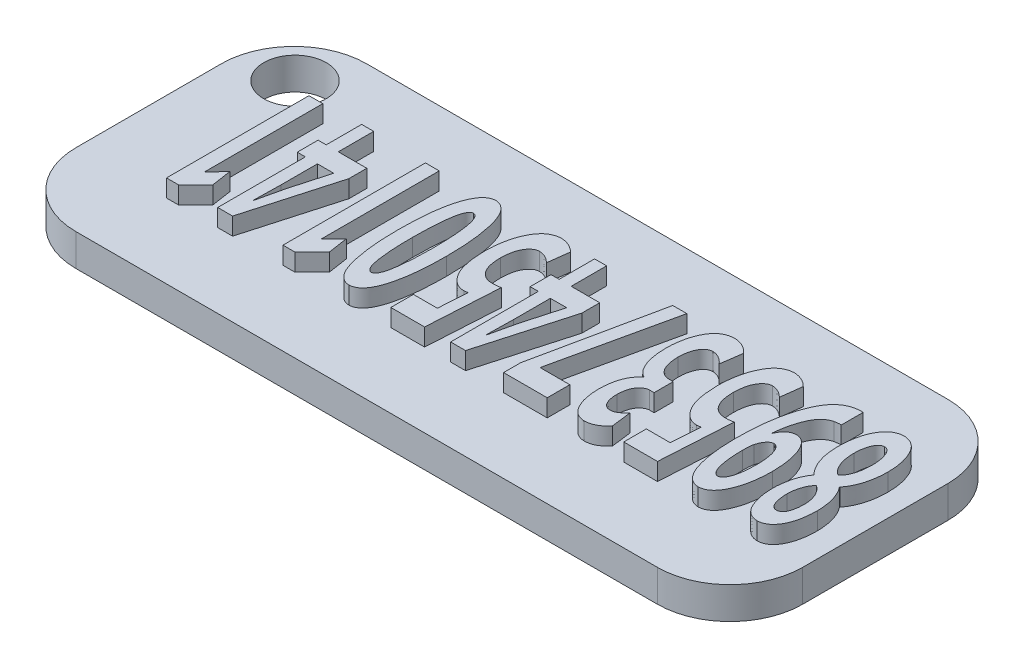
from build123d import *

# Parameters (mm, degrees)
SKETCH_1_W              = 50
SKETCH_1_H              = 20
EXTRUDE_1_DEPTH         = 2.2
FILLET_1_R              = 5
FILLET_2_R              = 5
FILLET_3_R              = 5
FILLET_4_R              = 5
SKETCH_4_R              = 2.151855383
CUT_EXTRUDE_1_DEPTH     = 3
EXTRUDE_1056_DEPTH      = 1.2
EXTRUDE_1056_DEPTH_BACK = 1.2


with BuildPart() as part:
    # Эскиз1 → Бобышка-Вытянуть1 (new body)
    with BuildSketch(Plane(origin=(0, 0, 0), x_dir=(1, 0, 0), z_dir=(0, 1, 0))):
        with Locations((25, 10)):
            Rectangle(SKETCH_1_W, SKETCH_1_H)
    extrude(amount=EXTRUDE_1_DEPTH)

    # Скругление1
    fillet_1_edges = [part.edges().sort_by_distance(p)[0] for p in [
        (0, 1.1, -20),
    ]]
    fillet(fillet_1_edges, radius=FILLET_1_R)

    # Скругление2
    fillet_2_edges = [part.edges().sort_by_distance(p)[0] for p in [
        (0, 1.1, 0),
    ]]
    fillet(fillet_2_edges, radius=FILLET_2_R)

    # Скругление3
    fillet_3_edges = [part.edges().sort_by_distance(p)[0] for p in [
        (50, 1.1, -20),
    ]]
    fillet(fillet_3_edges, radius=FILLET_3_R)

    # Скругление4
    fillet_4_edges = [part.edges().sort_by_distance(p)[0] for p in [
        (50, 1.1, 0),
    ]]
    fillet(fillet_4_edges, radius=FILLET_4_R)

    # Эскиз4 → Вырез-Вытянуть1 (cut)
    with BuildSketch(Plane(origin=(0, 2.2, 0), x_dir=(1, 0, 0), z_dir=(0, 1, 0))):
        with Locations((3.542470198, 16.528352227)):
            Circle(SKETCH_4_R)
    extrude(amount=-CUT_EXTRUDE_1_DEPTH, mode=Mode.SUBTRACT)

    # Эскиз5 → Extrude 1056 (add, two sides: drawn at the far end of the back side and taken through both)
    # profile 1 of 11: a face of its own
    with BuildSketch(Plane.XZ.offset(-2.2).offset(-EXTRUDE_1056_DEPTH_BACK)):
        with BuildLine():
            add(Edge.make_bspline(
                [(46.078309947, -9.677843866), (46.027974113, -9.605172508), (45.925734825, -9.457566573), (45.797719515, -9.21403545), (45.690766361, -8.949790128), (45.605330166, -8.667262078), (45.538818282, -8.374682095), (45.489532793, -8.076942657), (45.45786786, -7.777208198), (45.454564992, -7.576119586), (45.452912137, -7.475488811)],
                knots=[0, 0, 0, 0, 0.911528828, 1.851445597, 2.831681584, 3.849114504, 4.893651631, 5.925632796, 6.961924405, 8, 8, 8, 8], degree=3))
            add(Edge.make_bspline(
                [(45.452912137, -7.475488811), (45.456739433, -7.319432744), (45.464194853, -7.015441717), (45.526511786, -6.573878797), (45.63311746, -6.161319712), (45.753938359, -5.83962289), (45.873267915, -5.604845892), (45.977498211, -5.452969286), (46.093544961, -5.323103196), (46.221115754, -5.213766333), (46.361470193, -5.126354365), (46.514657083, -5.061353085), (46.680172404, -5.019646003), (46.795068916, -5.009135957), (46.853741958, -5.003768899)],
                knots=[0, 0, 0, 0, 1.791554521, 3.489877151, 5.107255168, 6.676714242, 7.425606061, 8.126241729, 8.785513885, 9.420356286, 10.049181088, 10.676513228, 11.324148379, 12, 12, 12, 12], degree=3))
            add(Edge.make_bspline(
                [(46.853741958, -5.003768899), (46.90797993, -5.007260305), (47.014463515, -5.014114866), (47.169787234, -5.050784431), (47.315929588, -5.110360712), (47.455258419, -5.189599), (47.583778459, -5.293674812), (47.705715522, -5.417268753), (47.817999658, -5.563759963), (47.924291395, -5.729516874), (48.016616167, -5.916192509), (48.100737096, -6.118543686), (48.169034399, -6.33794704), (48.228390088, -6.572481678), (48.272394452, -6.824061429), (48.306605506, -7.091379936), (48.326940882, -7.375267295), (48.331443098, -7.569726588), (48.333757313, -7.669681908)],
                knots=[0, 0, 0, 0, 0.776059093, 1.523610694, 2.26943235, 3.026161316, 3.806370488, 4.625991605, 5.503091466, 6.44030775, 7.436849706, 8.476373815, 9.570387437, 10.718835958, 11.933161742, 13.219262995, 14.570654791, 16, 16, 16, 16], degree=3))
            add(Edge.make_bspline(
                [(48.333757313, -7.669681908), (48.332400882, -7.773485108), (48.329714157, -7.979091408), (48.294470298, -8.282880004), (48.248183965, -8.579721921), (48.175551215, -8.86483122), (48.087174996, -9.135586497), (47.976756913, -9.385857701), (47.850277624, -9.616246555), (47.747160445, -9.753473674), (47.696502294, -9.820888941)],
                knots=[0, 0, 0, 0, 1.089978603, 2.15895528, 3.20972959, 4.244258845, 5.246508595, 6.198517637, 7.11498969, 8, 8, 8, 8], degree=3))
            Line((47.696502294, -9.820888941), (47.695145343, -9.85936227))
            add(Edge.make_bspline(
                [(47.695145343, -9.85936227), (47.747554237, -9.926459085), (47.856031089, -10.065337253), (47.992318934, -10.306361212), (48.120543883, -10.577558027), (48.235291236, -10.883599416), (48.332007715, -11.222904393), (48.400135986, -11.596003837), (48.444033938, -12.001236193), (48.450872319, -12.282433004), (48.454420985, -12.428355484)],
                knots=[0, 0, 0, 0, 0.747893007, 1.548002103, 2.428220339, 3.385024111, 4.419108458, 5.527032265, 6.716693888, 8, 8, 8, 8], degree=3))
            add(Edge.make_bspline(
                [(48.454420985, -12.428355484), (48.452674256, -12.516993812), (48.449226519, -12.691950305), (48.430923326, -12.949468758), (48.398000408, -13.197850059), (48.355874941, -13.436766086), (48.298960072, -13.665970943), (48.22900655, -13.885768002), (48.146139953, -14.095954879), (48.053448211, -14.295680741), (47.946991827, -14.478130498), (47.827908731, -14.639709615), (47.697781171, -14.778860945), (47.554387512, -14.893967333), (47.398514091, -14.984872048), (47.231251794, -15.053623861), (47.051286399, -15.097807415), (46.926883157, -15.107935165), (46.863168807, -15.113122193)],
                knots=[0, 0, 0, 0, 1.235435888, 2.438533473, 3.595508883, 4.725923701, 5.817781028, 6.884189936, 7.938117332, 8.96461166, 9.950003493, 10.876660607, 11.756436375, 12.597656396, 13.429845812, 14.262588117, 15.110167343, 16, 16, 16, 16], degree=3))
            add(Edge.make_bspline(
                [(46.863168807, -15.113122193), (46.80262288, -15.109171079), (46.684044908, -15.101432903), (46.511067483, -15.060678112), (46.347933835, -14.995360647), (46.191896755, -14.909032346), (46.047301537, -14.794897335), (45.911617757, -14.658556004), (45.784541788, -14.498597289), (45.668579213, -14.315558168), (45.563753042, -14.112223731), (45.470997983, -13.891170782), (45.394091896, -13.651866208), (45.330756558, -13.395988548), (45.279593831, -13.122797621), (45.242938773, -12.833195306), (45.217255905, -12.526213109), (45.213510802, -12.315917003), (45.211584793, -12.207767208)],
                knots=[0, 0, 0, 0, 0.789717121, 1.546644996, 2.30406014, 3.074123165, 3.86213959, 4.696104222, 5.576133471, 6.519015237, 7.51540899, 8.554319549, 9.6395583, 10.787721216, 11.987677943, 13.259577382, 14.590672234, 16, 16, 16, 16], degree=3))
            add(Edge.make_bspline(
                [(45.211584793, -12.207767208), (45.21631399, -12.061200702), (45.225433942, -11.778556663), (45.273766155, -11.372768263), (45.352120596, -11.002667897), (45.459635252, -10.669550107), (45.589719445, -10.373513923), (45.734618791, -10.113421233), (45.894005329, -9.888382936), (46.01865144, -9.764048816), (46.078854937, -9.703996008)],
                knots=[0, 0, 0, 0, 1.293490065, 2.494412024, 3.600539669, 4.62641707, 5.577396771, 6.448871158, 7.250811916, 8, 8, 8, 8], degree=3))
            Line((46.078854937, -9.703996008), (46.078309947, -9.677843866))
        make_face()
        with BuildLine():
            add(Edge.make_bspline(
                [(46.83621391, -13.800904757), (46.862390214, -13.798185585), (46.913759078, -13.792849434), (46.987088364, -13.766571208), (47.056547102, -13.729238508), (47.117966898, -13.673680896), (47.180206287, -13.610280654), (47.232947149, -13.529565327), (47.285573124, -13.438614817), (47.344553499, -13.294330749), (47.410925257, -13.095175517), (47.463520234, -12.833038866), (47.498548764, -12.547453652), (47.502265453, -12.348657789), (47.504194566, -12.245474606)],
                knots=[0, 0, 0, 0, 0.516878197, 1.014331308, 1.524422578, 2.060470795, 2.63878414, 3.270961343, 3.953097661, 4.707736148, 6.337157177, 8.083774507, 9.967318802, 12, 12, 12, 12], degree=3))
            add(Edge.make_bspline(
                [(47.504194566, -12.245474606), (47.501605234, -12.149267424), (47.496550758, -11.961467335), (47.469393374, -11.687559734), (47.419429409, -11.430678791), (47.355280098, -11.191444527), (47.271814748, -10.975113826), (47.170826099, -10.787544871), (47.053714874, -10.629827493), (46.959591571, -10.548418242), (46.914073794, -10.509048947)],
                knots=[0, 0, 0, 0, 1.22142396, 2.384266159, 3.488789828, 4.539640758, 5.524731502, 6.424298786, 7.237995119, 8, 8, 8, 8], degree=3))
            add(Edge.make_bspline(
                [(46.914073794, -10.509048947), (46.86044007, -10.548203883), (46.750645538, -10.628358636), (46.609486585, -10.785243872), (46.482183681, -10.970250236), (46.371339819, -11.186804007), (46.277961057, -11.434662914), (46.214225457, -11.716286991), (46.172416068, -12.028695365), (46.165451114, -12.247841318), (46.161811212, -12.362367538)],
                knots=[0, 0, 0, 0, 0.764838737, 1.565714712, 2.420999668, 3.352265673, 4.366974192, 5.470323704, 6.677984882, 8, 8, 8, 8], degree=3))
            add(Edge.make_bspline(
                [(46.161811212, -12.362367538), (46.163759344, -12.457382745), (46.167514338, -12.640523049), (46.202428312, -12.9042703), (46.256201504, -13.146406235), (46.3292193, -13.363319376), (46.421100573, -13.54734881), (46.538282039, -13.686539035), (46.67973401, -13.7773093), (46.784720718, -13.793083723), (46.83621391, -13.800904757)],
                knots=[0, 0, 0, 0, 1.321228345, 2.546646677, 3.694107777, 4.76689393, 5.725035891, 6.536813707, 7.27454525, 8, 8, 8, 8], degree=3))
        make_face(mode=Mode.SUBTRACT)
        with BuildLine():
            add(Edge.make_bspline(
                [(46.886500259, -6.293647279), (46.83538083, -6.301938363), (46.734376801, -6.318320253), (46.600140532, -6.408312885), (46.493740845, -6.543789202), (46.41679896, -6.722317663), (46.358261152, -6.92709015), (46.311903706, -7.152013712), (46.285864996, -7.392535246), (46.283622758, -7.558383626), (46.282474884, -7.64328673)],
                knots=[0, 0, 0, 0, 0.765528405, 1.512564887, 2.346431841, 3.307864738, 4.394490714, 5.524415916, 6.732669124, 8, 8, 8, 8], degree=3))
            add(Edge.make_bspline(
                [(46.282474884, -7.64328673), (46.285542594, -7.725718472), (46.291533991, -7.886711995), (46.322755467, -8.121747951), (46.368092179, -8.344452345), (46.434989814, -8.55067455), (46.511234044, -8.737323134), (46.60109943, -8.897440638), (46.696643827, -9.032946341), (46.775094048, -9.101929862), (46.81226382, -9.134614305)],
                knots=[0, 0, 0, 0, 1.216519099, 2.375925702, 3.494449087, 4.564888535, 5.570675503, 6.463263841, 7.271893284, 8, 8, 8, 8], degree=3))
            add(Edge.make_bspline(
                [(46.81226382, -9.134614305), (46.862439152, -9.096350175), (46.963589503, -9.019212066), (47.096313583, -8.876918569), (47.213065342, -8.713564267), (47.315895318, -8.52958974), (47.398878962, -8.323302575), (47.458545593, -8.094677067), (47.497098, -7.844424879), (47.501769248, -7.669832657), (47.504194566, -7.579184154)],
                knots=[0, 0, 0, 0, 0.854607252, 1.722835104, 2.626488507, 3.572752242, 4.57465509, 5.633219383, 6.771164507, 8, 8, 8, 8], degree=3))
            add(Edge.make_bspline(
                [(47.504194566, -7.579184154), (47.503195757, -7.499277873), (47.501255068, -7.344019773), (47.473234473, -7.117775601), (47.431519103, -6.903753043), (47.369090488, -6.707727668), (47.290569229, -6.53547269), (47.182295761, -6.403004689), (47.043184988, -6.318466445), (46.940284878, -6.303102084), (46.887678615, -6.295247266)],
                knots=[0, 0, 0, 0, 1.230812713, 2.391472128, 3.50850541, 4.586815455, 5.557221012, 6.409314627, 7.186784035, 8, 8, 8, 8], degree=3))
            Line((46.887678615, -6.295247266), (46.886500259, -6.293647279))
        make_face(mode=Mode.SUBTRACT)
    # profile 2 of 11: a face of its own
    with BuildSketch(Plane.XZ.offset(-2.2).offset(-EXTRUDE_1056_DEPTH_BACK)):
        with BuildLine():
            add(Edge.make_bspline(
                [(44.04725437, -15.11174683), (43.987385205, -15.114070393), (43.868898808, -15.118668932), (43.693434551, -15.103937408), (43.523252435, -15.077828695), (43.358741609, -15.039003764), (43.201388033, -14.983318238), (43.050111553, -14.915129471), (42.903936107, -14.834674512), (42.766996185, -14.736787277), (42.632629914, -14.629426485), (42.508059907, -14.504726533), (42.38788946, -14.367318384), (42.273368197, -14.217136563), (42.16508345, -14.052358087), (42.066568067, -13.872002181), (41.96939987, -13.68052939), (41.851289199, -13.402249017), (41.717343953, -13.031760823), (41.577455337, -12.561667209), (41.462107324, -12.061386408), (41.365507994, -11.533031322), (41.293318956, -10.975995836), (41.240314731, -10.390514117), (41.210397464, -9.775330417), (41.207191415, -9.35523444), (41.205550872, -9.140270414)],
                knots=[0, 0, 0, 0, 0.587702947, 1.163116348, 1.725075362, 2.277262808, 2.819713187, 3.360969282, 3.905101247, 4.454524283, 5.011482261, 5.591737658, 6.182009412, 6.802709751, 7.444427068, 8.115602503, 8.819201884, 9.551563824, 11.081795736, 12.684480665, 14.363626865, 16.119590269, 17.955514458, 19.875934814, 21.889706872, 24, 24, 24, 24], degree=3))
            add(Edge.make_bspline(
                [(41.205550872, -9.140270414), (41.207264897, -8.991309733), (41.210614758, -8.700183418), (41.228928778, -8.27442403), (41.26139615, -7.870179001), (41.303851059, -7.487012124), (41.35985007, -7.12516581), (41.429753321, -6.785560877), (41.510350616, -6.467461477), (41.603134364, -6.172814895), (41.708826173, -5.906123561), (41.827749924, -5.671195277), (41.958955197, -5.470530026), (42.102547312, -5.302101472), (42.26283362, -5.173038944), (42.433532632, -5.075831142), (42.618009403, -5.01296775), (42.746684608, -5.000605939), (42.81188601, -4.994342049)],
                knots=[0, 0, 0, 0, 1.488694986, 2.909481093, 4.257746305, 5.540848802, 6.761339651, 7.915469393, 9.004609899, 10.039448099, 11.000449599, 11.868389147, 12.666188125, 13.391717201, 14.070478316, 14.711614416, 15.347158253, 16, 16, 16, 16], degree=3))
            add(Edge.make_bspline(
                [(42.81188601, -4.994342049), (42.873943174, -5.000099892), (42.997342197, -5.011549209), (43.174435585, -5.071753842), (43.341841896, -5.156147597), (43.497681637, -5.27312241), (43.642287555, -5.41903082), (43.776639778, -5.595135643), (43.901300582, -5.799757373), (44.011533243, -6.03278609), (44.113476948, -6.28555358), (44.198583084, -6.556030295), (44.274785722, -6.839444532), (44.337084136, -7.137093239), (44.382818759, -7.449561619), (44.419726254, -7.775163248), (44.439445614, -8.115654083), (44.444116993, -8.347137517), (44.446501695, -8.465307997)],
                knots=[0, 0, 0, 0, 0.71661271, 1.42496533, 2.141431373, 2.872130828, 3.661492946, 4.503891963, 5.421382964, 6.41994004, 7.473922347, 8.56282292, 9.6881508, 10.858187346, 12.067902601, 13.329498283, 14.63672978, 16, 16, 16, 16], degree=3))
            add(Edge.make_bspline(
                [(44.446501695, -8.465307997), (44.444301581, -8.579725962), (44.440018776, -8.802455229), (44.418138685, -9.126841338), (44.389744776, -9.432845618), (44.346232134, -9.719112434), (44.291514129, -9.986576149), (44.226515668, -10.234971415), (44.149036141, -10.464286834), (44.061521886, -10.673296099), (43.963022591, -10.859813171), (43.86081538, -11.024451663), (43.750302846, -11.165118524), (43.632325733, -11.27981019), (43.50792487, -11.371672429), (43.375998762, -11.435440305), (43.238321206, -11.480471442), (43.142806007, -11.486436477), (43.094691492, -11.489441284)],
                knots=[0, 0, 0, 0, 1.529770763, 2.977895321, 4.345668482, 5.637335493, 6.846838563, 7.994249315, 9.067689445, 10.080490039, 11.020068362, 11.884879202, 12.668265517, 13.405073479, 14.079029672, 14.725341234, 15.357907549, 16, 16, 16, 16], degree=3))
            add(Edge.make_bspline(
                [(43.094691492, -11.489441284), (43.044787182, -11.486183321), (42.945933546, -11.479729739), (42.803226891, -11.439100379), (42.670705849, -11.373559165), (42.548260623, -11.283451948), (42.439085027, -11.168339541), (42.333351592, -11.038338918), (42.241947327, -10.886319281), (42.190018525, -10.776615668), (42.163318771, -10.720210373)],
                knots=[0, 0, 0, 0, 0.935406275, 1.852912324, 2.759079899, 3.694486174, 4.685786001, 5.725263117, 6.830419519, 8, 8, 8, 8], degree=3))
            Line((42.163318771, -10.720210373), (42.143203863, -10.732850085))
            add(Edge.make_bspline(
                [(42.143203863, -10.732850085), (42.152913081, -10.826145832), (42.171961613, -11.009182943), (42.213021068, -11.276889607), (42.256329034, -11.533427069), (42.312327657, -11.777714281), (42.373431464, -12.010753199), (42.443989973, -12.232601603), (42.520328195, -12.443143418), (42.604992277, -12.640929958), (42.696024941, -12.824197987), (42.797560211, -12.98838531), (42.907535712, -13.132919259), (43.024857499, -13.258958894), (43.151200313, -13.365300223), (43.286637025, -13.450625789), (43.428878747, -13.518420365), (43.529094466, -13.547109732), (43.579231551, -13.561462782)],
                knots=[0, 0, 0, 0, 1.339989936, 2.628928885, 3.868993049, 5.056241457, 6.208438896, 7.310307185, 8.381264534, 9.407037606, 10.382860463, 11.30231499, 12.160773156, 12.973890012, 13.757980097, 14.51278177, 15.255957167, 16, 16, 16, 16], degree=3))
            add(Edge.make_bspline(
                [(43.579231551, -13.561462782), (43.61258245, -13.566861786), (43.67367764, -13.576752169), (43.756732427, -13.593836438), (43.824452891, -13.601489775), (43.891708091, -13.613413366), (43.965642464, -13.61504435), (44.021131507, -13.605697441), (44.048688651, -13.601055549)],
                knots=[0, 0, 0, 0, 1.282317147, 2.349064382, 3.21602214, 3.867087612, 4.940746315, 6, 6, 6, 6], degree=3))
            Line((44.048688651, -13.601055549), (44.04725437, -15.11174683))
        make_face()
        with BuildLine():
            add(Edge.make_bspline(
                [(42.844590917, -6.304677798), (42.81632972, -6.308919917), (42.759015095, -6.317523072), (42.678836933, -6.357293238), (42.605990003, -6.416423603), (42.536602226, -6.493216758), (42.476050485, -6.592472346), (42.419178939, -6.710531156), (42.368846462, -6.849011498), (42.308227289, -7.066665145), (42.244553984, -7.373100249), (42.194071408, -7.777220869), (42.161821034, -8.225345058), (42.15785408, -8.538776352), (42.155777292, -8.702864602)],
                knots=[0, 0, 0, 0, 0.388324956, 0.787535614, 1.2030177, 1.664837744, 2.193361997, 2.784441419, 3.452382468, 4.202091393, 5.868356787, 7.720494359, 9.759583653, 12, 12, 12, 12], degree=3))
            add(Edge.make_bspline(
                [(42.155777292, -8.702864602), (42.155368544, -8.74812072), (42.154596287, -8.833624136), (42.15968612, -8.954239716), (42.162435199, -9.060539025), (42.170279424, -9.177455748), (42.179085395, -9.300512339), (42.199485933, -9.390539813), (42.208567648, -9.430617376)],
                knots=[0, 0, 0, 0, 1.11380462, 2.104336476, 2.971181265, 3.730606527, 4.989733304, 6, 6, 6, 6], degree=3))
            add(Edge.make_bspline(
                [(42.208567648, -9.430617376), (42.238302449, -9.525684566), (42.295931093, -9.709933092), (42.4157911, -9.915830309), (42.528538944, -10.050337156), (42.621005158, -10.125337554), (42.723563966, -10.173398169), (42.796336215, -10.182241067), (42.832625079, -10.186650697)],
                knots=[0, 0, 0, 0, 1.717293694, 3.328265295, 4.075010403, 4.73980506, 5.371586794, 6, 6, 6, 6], degree=3))
            add(Edge.make_bspline(
                [(42.832625079, -10.186650697), (42.857327254, -10.184568066), (42.906667609, -10.1804082), (42.978465354, -10.154699735), (43.044277372, -10.112341419), (43.106396021, -10.054870548), (43.165721311, -9.984224083), (43.221107135, -9.897287482), (43.271162554, -9.795137333), (43.33631677, -9.632755834), (43.402506594, -9.394999705), (43.459803499, -9.070602549), (43.494534602, -8.697313717), (43.499373301, -8.432077134), (43.501931386, -8.291853969)],
                knots=[0, 0, 0, 0, 0.413789282, 0.826506569, 1.261562931, 1.716042024, 2.238855857, 2.802250335, 3.437615293, 4.141140511, 5.729823065, 7.558733105, 9.652026376, 12, 12, 12, 12], degree=3))
            add(Edge.make_bspline(
                [(43.501931386, -8.291853969), (43.499172297, -8.153522521), (43.493908565, -7.889616713), (43.460775977, -7.513375446), (43.405536667, -7.177101272), (43.340129957, -6.924955276), (43.279157951, -6.746836863), (43.227842301, -6.634724435), (43.176350338, -6.536377609), (43.117340877, -6.457508469), (43.056964627, -6.392355076), (42.99033886, -6.347000991), (42.91982955, -6.316280085), (42.870621648, -6.309816763), (42.845822668, -6.306559485)],
                knots=[0, 0, 0, 0, 2.244031887, 4.281116543, 6.121417338, 7.765846703, 8.501017567, 9.171798035, 9.76494997, 10.29714384, 10.765780613, 11.198437351, 11.596041788, 12, 12, 12, 12], degree=3))
            Line((42.845822668, -6.306559485), (42.844590917, -6.304677798))
        make_face(mode=Mode.SUBTRACT)
    # profile 3 of 11: a face of its own
    with BuildSketch(Plane.XZ.offset(-2.2).offset(-EXTRUDE_1056_DEPTH_BACK)):
        with BuildLine():
            add(Edge.make_bspline(
                [(40.192335424, -10.097629571), (40.108779367, -10.080350986), (39.928861905, -10.043145792), (39.745130929, -10.038375834), (39.646727056, -10.035821107)],
                knots=[0, 0, 0, 0, 0.928826533, 2, 2, 2, 2], degree=3))
            add(Edge.make_bspline(
                [(39.646727056, -10.035821107), (39.596356053, -10.037144258), (39.498842118, -10.039705763), (39.357107939, -10.063141988), (39.225526757, -10.100461888), (39.102393915, -10.151947208), (38.989423473, -10.218450867), (38.884167932, -10.297443649), (38.791440863, -10.394209158), (38.706195987, -10.502836195), (38.633369841, -10.627502307), (38.566555859, -10.762910831), (38.512386723, -10.912277426), (38.469995342, -11.074174259), (38.433102138, -11.247566327), (38.409926726, -11.434895562), (38.394464745, -11.634355423), (38.392221711, -11.771586486), (38.391070716, -11.842005452)],
                knots=[0, 0, 0, 0, 0.971191819, 1.880143916, 2.762839131, 3.60505127, 4.447263409, 5.286327734, 6.135146923, 7.025222593, 7.94430753, 8.914969409, 9.935323239, 11.002990034, 12.142007005, 13.352662052, 14.641540791, 16, 16, 16, 16], degree=3))
            add(Edge.make_bspline(
                [(38.391070716, -11.842005452), (38.393043981, -11.909272993), (38.396884389, -12.040190474), (38.411460772, -12.23096965), (38.436079789, -12.409638534), (38.467810303, -12.575884139), (38.50725334, -12.730478322), (38.556081545, -12.872815282), (38.611926704, -13.004160281), (38.678287624, -13.120952078), (38.750159379, -13.224092842), (38.823488973, -13.316422958), (38.902159433, -13.393647183), (38.984829667, -13.455748737), (39.067355654, -13.509965552), (39.157602931, -13.541523956), (39.248784571, -13.566999866), (39.311573168, -13.569587136), (39.343182505, -13.570889631)],
                knots=[0, 0, 0, 0, 1.492946742, 2.905603862, 4.242536531, 5.492208905, 6.658933463, 7.7788985, 8.82796704, 9.820667976, 10.75276788, 11.615096908, 12.433471051, 13.189229796, 13.909019935, 14.610757751, 15.300620973, 16, 16, 16, 16], degree=3))
            add(Edge.make_bspline(
                [(39.343182505, -13.570889631), (39.38983853, -13.568380356), (39.482097569, -13.56341844), (39.617626699, -13.533825924), (39.747972164, -13.488642345), (39.908712456, -13.409054131), (40.087661862, -13.294393111), (40.206952933, -13.179946467), (40.263243007, -13.12594234)],
                knots=[0, 0, 0, 0, 0.801470045, 1.584851196, 2.37349572, 3.165310909, 4.662390589, 6, 6, 6, 6], degree=3))
            Line((40.263243007, -13.12594234), (40.449658954, -14.587103996))
            add(Edge.make_bspline(
                [(40.449658954, -14.587103996), (40.417096041, -14.621108057), (40.350838838, -14.690297629), (40.2359918, -14.783586466), (40.105123663, -14.867027635), (39.962626792, -14.946663917), (39.808394683, -15.015512651), (39.64214658, -15.060505063), (39.470306048, -15.095572759), (39.352168796, -15.099711688), (39.292277519, -15.101809973)],
                knots=[0, 0, 0, 0, 0.867626664, 1.765398496, 2.720085674, 3.726414318, 4.774902414, 5.823966795, 6.896830548, 8, 8, 8, 8], degree=3))
            add(Edge.make_bspline(
                [(39.292277519, -15.101809973), (39.221510791, -15.095970858), (39.082375373, -15.084490493), (38.881797156, -15.02715985), (38.69309556, -14.943712842), (38.515668747, -14.83081222), (38.350519784, -14.687994683), (38.199822831, -14.513981942), (38.060076919, -14.312731964), (37.933175297, -14.084880226), (37.819987239, -13.835916731), (37.719541463, -13.570860738), (37.634882259, -13.291113855), (37.565814728, -12.997565106), (37.510807312, -12.690453339), (37.471785794, -12.369443935), (37.446831675, -12.034072997), (37.442864076, -11.805599251), (37.440844297, -11.689290491)],
                knots=[0, 0, 0, 0, 0.800118372, 1.57312353, 2.341915381, 3.123472314, 3.938586515, 4.798407496, 5.715777283, 6.700728512, 7.739066045, 8.801352045, 9.899074363, 11.036803875, 12.204674243, 13.420209821, 14.686710393, 16, 16, 16, 16], degree=3))
            add(Edge.make_bspline(
                [(37.440844297, -11.689290491), (37.444230945, -11.562928248), (37.450775258, -11.318747534), (37.476688876, -10.965686938), (37.517892952, -10.637743387), (37.573539342, -10.33543868), (37.64374808, -10.057774711), (37.725222218, -9.804857657), (37.822605491, -9.576898803), (37.937227253, -9.376389846), (38.059134548, -9.199215643), (38.187289425, -9.045129367), (38.322065034, -8.915482301), (38.462376667, -8.808978448), (38.607735816, -8.723793371), (38.761174563, -8.667597532), (38.919204195, -8.631858513), (39.02687709, -8.627672895), (39.081116092, -8.625564437)],
                knots=[0, 0, 0, 0, 1.587176406, 3.067038503, 4.44328291, 5.735702164, 6.924301074, 8.037326695, 9.069410064, 10.030633494, 10.932524697, 11.767135362, 12.542965892, 13.275314645, 13.975181296, 14.649441249, 15.319671309, 16, 16, 16, 16], degree=3))
            add(Edge.make_bspline(
                [(39.081116092, -8.625564437), (39.127902894, -8.626817487), (39.219370871, -8.629267193), (39.307616765, -8.653378888), (39.350723985, -8.665157205)],
                knots=[0, 0, 0, 0, 1.023020369, 2, 2, 2, 2], degree=3))
            Line((39.350723985, -8.665157205), (39.220939099, -6.666668815))
            Line((39.220939099, -6.666668815), (37.574777364, -6.666668815))
            Line((37.574777364, -6.666668815), (37.574777364, -5.113122193))
            Line((37.574777364, -5.113122193), (39.896413365, -5.113122193))
            Line((39.896413365, -5.113122193), (40.192335424, -10.097629571))
        make_face()
    # profile 4 of 11: a face of its own
    with BuildSketch(Plane.XZ.offset(-2.2).offset(-EXTRUDE_1056_DEPTH_BACK)):
        with BuildLine():
            add(Edge.make_bspline(
                [(36.057639739, -7.064916378), (36.004306192, -7.003690436), (35.892624505, -6.875481891), (35.72708894, -6.735891329), (35.578356937, -6.638949579), (35.459759996, -6.582360446), (35.335839349, -6.547789274), (35.251248268, -6.540313379), (35.208943434, -6.536574611)],
                knots=[0, 0, 0, 0, 1.418338336, 2.970033458, 3.765529243, 4.517574839, 5.258624551, 6, 6, 6, 6], degree=3))
            add(Edge.make_bspline(
                [(35.208943434, -6.536574611), (35.152998735, -6.54167271), (35.044117165, -6.551594813), (34.8926061, -6.618443946), (34.768847334, -6.729589428), (34.671158906, -6.8764594), (34.597587843, -7.053763933), (34.543515452, -7.25598961), (34.511830683, -7.483302537), (34.507812222, -7.642554187), (34.505700468, -7.726243005)],
                knots=[0, 0, 0, 0, 0.872432656, 1.69795961, 2.532006638, 3.435155328, 4.428047478, 5.515317144, 6.694266783, 8, 8, 8, 8], degree=3))
            add(Edge.make_bspline(
                [(34.505700468, -7.726243005), (34.508471659, -7.782825374), (34.513867604, -7.893000169), (34.527817212, -8.052461919), (34.551921672, -8.200738881), (34.58698832, -8.336185), (34.624562342, -8.461592471), (34.675272375, -8.573741601), (34.730317281, -8.67590245), (34.814731398, -8.790362524), (34.925894879, -8.909608594), (35.070192861, -9.01539981), (35.220118195, -9.084666019), (35.323911958, -9.092876863), (35.374855983, -9.096906907)],
                knots=[0, 0, 0, 0, 1.14248271, 2.224593996, 3.226858075, 4.167522928, 5.045377976, 5.862577234, 6.645541848, 7.380784149, 8.725617819, 9.914678345, 10.976483021, 12, 12, 12, 12], degree=3))
            Line((35.374855983, -9.096906907), (35.682955617, -9.095023378))
            Line((35.682955617, -9.095023378), (35.682955617, -10.407240815))
            Line((35.682955617, -10.407240815), (35.354868116, -10.407240815))
            add(Edge.make_bspline(
                [(35.354868116, -10.407240815), (35.292198871, -10.411724456), (35.166187213, -10.420739902), (34.987264381, -10.503640202), (34.822098399, -10.631771995), (34.701723239, -10.776951097), (34.613516238, -10.915119763), (34.555184208, -11.036792837), (34.50709821, -11.171124914), (34.464913906, -11.318370985), (34.431559564, -11.479055422), (34.40787905, -11.653608291), (34.390095779, -11.840406568), (34.38675921, -11.969537942), (34.385036796, -12.036198549)],
                knots=[0, 0, 0, 0, 1.0725391, 2.156599005, 3.328049282, 4.646656099, 5.375165082, 6.143613012, 6.960669464, 7.826032993, 8.775492873, 9.77952784, 10.853740813, 12, 12, 12, 12], degree=3))
            add(Edge.make_bspline(
                [(34.385036796, -12.036198549), (34.38719891, -12.136910997), (34.391381021, -12.33171607), (34.433975166, -12.612389019), (34.501024159, -12.870937019), (34.580292765, -13.069012036), (34.659721163, -13.209687844), (34.722594072, -13.303047591), (34.795370454, -13.381550798), (34.87581608, -13.446156629), (34.961996134, -13.499725402), (35.056496227, -13.53758635), (35.156821986, -13.562620732), (35.226397309, -13.568104494), (35.26173379, -13.570889631)],
                knots=[0, 0, 0, 0, 1.856984394, 3.59190931, 5.223149363, 6.77779583, 7.50984741, 8.201383688, 8.849567299, 9.476129889, 10.100543029, 10.714205536, 11.346960239, 12, 12, 12, 12], degree=3))
            add(Edge.make_bspline(
                [(35.26173379, -13.570889631), (35.309131881, -13.56744212), (35.403932228, -13.560546795), (35.542491113, -13.521446089), (35.679540762, -13.470649809), (35.807364001, -13.394997675), (35.927876633, -13.313281413), (36.03340052, -13.222362125), (36.129087399, -13.134414947), (36.181273063, -13.068801619), (36.2063041, -13.037329955)],
                knots=[0, 0, 0, 0, 1.017995082, 2.03607963, 3.078738206, 4.148474372, 5.215482485, 6.202219836, 7.13768843, 8, 8, 8, 8], degree=3))
            Line((36.2063041, -13.037329955), (36.41789268, -14.499887228))
            add(Edge.make_bspline(
                [(36.41789268, -14.499887228), (36.38559447, -14.541328866), (36.319602606, -14.626002628), (36.196722354, -14.735146303), (36.06093928, -14.838442716), (35.908777731, -14.927409461), (35.744999595, -15.004481394), (35.569667144, -15.05776883), (35.385703099, -15.093625419), (35.260021987, -15.099040553), (35.195745844, -15.101809973)],
                knots=[0, 0, 0, 0, 0.892743867, 1.824058698, 2.786979092, 3.794344992, 4.818837677, 5.861109463, 6.906123353, 8, 8, 8, 8], degree=3))
            add(Edge.make_bspline(
                [(35.195745844, -15.101809973), (35.127015534, -15.096686821), (34.991935444, -15.086617962), (34.795999651, -15.041034136), (34.61312012, -14.967991605), (34.4421978, -14.872100926), (34.285330697, -14.748099556), (34.14018536, -14.600699387), (34.007042192, -14.427314201), (33.890681147, -14.228757005), (33.783604052, -14.013523457), (33.690962196, -13.782736443), (33.615092115, -13.538169594), (33.547123489, -13.282152932), (33.500563997, -13.011195372), (33.461645035, -12.728415962), (33.439012636, -12.43186478), (33.436230143, -12.229799896), (33.434810377, -12.126696304)],
                knots=[0, 0, 0, 0, 0.864891614, 1.699827002, 2.514931852, 3.331602707, 4.152801883, 5.018089748, 5.924467121, 6.891171371, 7.904462885, 8.942396474, 10.011011592, 11.11967405, 12.267122632, 13.461805445, 14.704886406, 16, 16, 16, 16], degree=3))
            add(Edge.make_bspline(
                [(33.434810377, -12.126696304), (33.436716849, -12.044342726), (33.44043083, -11.883910469), (33.455997272, -11.649378782), (33.477559428, -11.426510089), (33.510342232, -11.215323893), (33.548618713, -11.015419676), (33.598437833, -10.828152885), (33.654314291, -10.652909991), (33.718486791, -10.489712997), (33.790143722, -10.340719636), (33.863428314, -10.203224023), (33.941927376, -10.080102161), (34.027742989, -9.973189225), (34.114246372, -9.87678645), (34.20724785, -9.796168712), (34.30283225, -9.726455907), (34.371928929, -9.692398463), (34.405775865, -9.67571546)],
                knots=[0, 0, 0, 0, 1.432570841, 2.790778257, 4.087236787, 5.325481683, 6.506639938, 7.625461742, 8.69358506, 9.704410807, 10.672490794, 11.567529549, 12.41343068, 13.207233272, 13.949868162, 14.662453553, 15.344804271, 16, 16, 16, 16], degree=3))
            Line((34.405775865, -9.67571546), (34.404336061, -9.650183796))
            add(Edge.make_bspline(
                [(34.404336061, -9.650183796), (34.338072666, -9.596690805), (34.202212833, -9.487014132), (34.032873184, -9.278336086), (33.885364406, -9.03698994), (33.766752845, -8.761544198), (33.674322453, -8.457595821), (33.60324208, -8.130603545), (33.565180001, -7.779926815), (33.558770528, -7.539045516), (33.555474049, -7.415156975)],
                knots=[0, 0, 0, 0, 0.823649056, 1.688727585, 2.588363477, 3.559562308, 4.586652083, 5.664474026, 6.798807098, 8, 8, 8, 8], degree=3))
            add(Edge.make_bspline(
                [(33.555474049, -7.415156975), (33.556535817, -7.333428229), (33.55862903, -7.172304786), (33.575842829, -6.935676797), (33.603722889, -6.709051499), (33.64347812, -6.492480277), (33.69449614, -6.286211755), (33.753792731, -6.088256919), (33.828666531, -5.90210248), (33.909728245, -5.725012906), (34.003148481, -5.563590605), (34.106872659, -5.420241337), (34.222702482, -5.29826388), (34.350026861, -5.196789186), (34.489272564, -5.11778749), (34.637462922, -5.055738566), (34.797433554, -5.017988909), (34.90772527, -5.009813956), (34.963845349, -5.005654268)],
                knots=[0, 0, 0, 0, 1.271627412, 2.506939074, 3.689568979, 4.823148725, 5.930785385, 6.994871486, 8.035420386, 9.05038077, 10.023196899, 10.932710029, 11.797321464, 12.632737579, 13.456336747, 14.280806312, 15.125217286, 16, 16, 16, 16], degree=3))
            add(Edge.make_bspline(
                [(34.963845349, -5.005654268), (35.028738161, -5.00978693), (35.157763565, -5.018003838), (35.347468654, -5.057233476), (35.528315494, -5.1255076), (35.700306881, -5.212988484), (35.85735902, -5.318401935), (36.001722564, -5.42979333), (36.126065278, -5.551701085), (36.196487762, -5.640906086), (36.230813908, -5.684387425)],
                knots=[0, 0, 0, 0, 1.04958293, 2.086869976, 3.114625545, 4.163373582, 5.196679088, 6.165384507, 7.105750375, 8, 8, 8, 8], degree=3))
            Line((36.230813908, -5.684387425), (36.057639739, -7.064916378))
        make_face()
    # profile 5 of 11: a face of its own
    with BuildSketch(Plane.XZ.offset(-2.2).offset(-EXTRUDE_1056_DEPTH_BACK)):
        Polygon((30.27033266, -6.666668815), (30.27033266, -6.69273258), (32.099191155, -14.928882522), (31.130597109, -14.928882522), (29.308110943, -6.284660472), (29.308110943, -5.113122193), (32.309621633, -5.113122193), (32.309621633, -6.666668815), align=None)
    # profile 6 of 11: a face of its own
    with BuildSketch(Plane.XZ.offset(-2.2).offset(-EXTRUDE_1056_DEPTH_BACK)):
        Polygon((25.104389363, -12.579186916), (25.104389363, -11.146303966), (25.66406804, -11.146303966), (25.66406804, -5.11618776), (26.686625276, -5.11618776), (28.455724542, -11.350927357), (28.455724542, -12.579186916), (26.493632628, -12.579186916), (26.493632628, -15.016149003), (25.66406804, -15.016149003), (25.66406804, -12.579186916), align=None)
        with BuildLine():
            add(Edge.make_bspline(
                [(26.892484099, -8.569239012), (26.823423843, -8.280892344), (26.681312056, -7.687534271), (26.549881389, -7.091718303), (26.482320409, -6.785443435)],
                knots=[0, 0, 0, 0, 0.971914534, 2, 2, 2, 2], degree=3))
            Line((26.482320409, -6.785443435), (26.45735767, -6.784268761))
            add(Edge.make_bspline(
                [(26.45735767, -6.784268761), (26.466811576, -7.092581771), (26.485608351, -7.705586598), (26.490968424, -8.318855829), (26.493632628, -8.623679067)],
                knots=[0, 0, 0, 0, 1.005907284, 2, 2, 2, 2], degree=3))
            Line((26.493632628, -8.623679067), (26.493632628, -11.146303966))
            Line((26.493632628, -11.146303966), (27.606556894, -11.146303966))
            Line((27.606556894, -11.146303966), (27.606556894, -11.11945954))
            Line((27.606556894, -11.11945954), (26.892484099, -8.569239012))
        make_face(mode=Mode.SUBTRACT)
    # profile 7 of 11: a face of its own
    with BuildSketch(Plane.XZ.offset(-2.2).offset(-EXTRUDE_1056_DEPTH_BACK)):
        with BuildLine():
            add(Edge.make_bspline(
                [(24.168199743, -10.097629571), (24.084643687, -10.080350986), (23.904726225, -10.043145792), (23.720995249, -10.038375834), (23.622591376, -10.035821107)],
                knots=[0, 0, 0, 0, 0.928826533, 2, 2, 2, 2], degree=3))
            add(Edge.make_bspline(
                [(23.622591376, -10.035821107), (23.572220372, -10.037144258), (23.474706438, -10.039705763), (23.332972259, -10.063141988), (23.201391077, -10.100461888), (23.078258235, -10.151947208), (22.965287793, -10.218450867), (22.860032252, -10.297443649), (22.767305183, -10.394209158), (22.682060306, -10.502836195), (22.609234161, -10.627502307), (22.542420179, -10.762910831), (22.488251043, -10.912277426), (22.445859662, -11.074174259), (22.408966458, -11.247566327), (22.385791045, -11.434895562), (22.370329065, -11.634355423), (22.36808603, -11.771586486), (22.366935036, -11.842005452)],
                knots=[0, 0, 0, 0, 0.971191819, 1.880143916, 2.762839131, 3.60505127, 4.447263409, 5.286327734, 6.135146923, 7.025222593, 7.94430753, 8.914969409, 9.935323239, 11.002990034, 12.142007005, 13.352662052, 14.641540791, 16, 16, 16, 16], degree=3))
            add(Edge.make_bspline(
                [(22.366935036, -11.842005452), (22.368908301, -11.909272993), (22.372748709, -12.040190474), (22.387325092, -12.23096965), (22.411944109, -12.409638534), (22.443674623, -12.575884139), (22.48311766, -12.730478322), (22.531945865, -12.872815282), (22.587791023, -13.004160281), (22.654151944, -13.120952078), (22.726023699, -13.224092842), (22.799353293, -13.316422958), (22.878023753, -13.393647183), (22.960693986, -13.455748737), (23.043219974, -13.509965552), (23.133467251, -13.541523956), (23.224648891, -13.566999866), (23.287437487, -13.569587136), (23.319046825, -13.570889631)],
                knots=[0, 0, 0, 0, 1.492946742, 2.905603862, 4.242536531, 5.492208905, 6.658933463, 7.7788985, 8.82796704, 9.820667976, 10.75276788, 11.615096908, 12.433471051, 13.189229796, 13.909019935, 14.610757751, 15.300620973, 16, 16, 16, 16], degree=3))
            add(Edge.make_bspline(
                [(23.319046825, -13.570889631), (23.36570285, -13.568380356), (23.457961889, -13.56341844), (23.593491018, -13.533825924), (23.723836484, -13.488642345), (23.884576775, -13.409054131), (24.063526182, -13.294393111), (24.182817252, -13.179946467), (24.239107326, -13.12594234)],
                knots=[0, 0, 0, 0, 0.801470045, 1.584851196, 2.37349572, 3.165310909, 4.662390589, 6, 6, 6, 6], degree=3))
            Line((24.239107326, -13.12594234), (24.425523273, -14.587103996))
            add(Edge.make_bspline(
                [(24.425523273, -14.587103996), (24.392960361, -14.621108057), (24.326703158, -14.690297629), (24.211856119, -14.783586466), (24.080987983, -14.867027635), (23.938491111, -14.946663917), (23.784259002, -15.015512651), (23.6180109, -15.060505063), (23.446170368, -15.095572759), (23.328033116, -15.099711688), (23.268141838, -15.101809973)],
                knots=[0, 0, 0, 0, 0.867626664, 1.765398496, 2.720085674, 3.726414318, 4.774902414, 5.823966795, 6.896830548, 8, 8, 8, 8], degree=3))
            add(Edge.make_bspline(
                [(23.268141838, -15.101809973), (23.197375111, -15.095970858), (23.058239692, -15.084490493), (22.857661475, -15.02715985), (22.66895988, -14.943712842), (22.491533067, -14.83081222), (22.326384103, -14.687994683), (22.175687151, -14.513981942), (22.035941239, -14.312731964), (21.909039616, -14.084880226), (21.795851558, -13.835916731), (21.695405782, -13.570860738), (21.610746578, -13.291113855), (21.541679047, -12.997565106), (21.486671632, -12.690453339), (21.447650113, -12.369443935), (21.422695994, -12.034072997), (21.418728396, -11.805599251), (21.416708617, -11.689290491)],
                knots=[0, 0, 0, 0, 0.800118372, 1.57312353, 2.341915381, 3.123472314, 3.938586515, 4.798407496, 5.715777283, 6.700728512, 7.739066045, 8.801352045, 9.899074363, 11.036803875, 12.204674243, 13.420209821, 14.686710393, 16, 16, 16, 16], degree=3))
            add(Edge.make_bspline(
                [(21.416708617, -11.689290491), (21.420095265, -11.562928248), (21.426639578, -11.318747534), (21.452553196, -10.965686938), (21.493757272, -10.637743387), (21.549403661, -10.33543868), (21.6196124, -10.057774711), (21.701086537, -9.804857657), (21.79846981, -9.576898803), (21.913091573, -9.376389846), (22.034998868, -9.199215643), (22.163153744, -9.045129367), (22.297929354, -8.915482301), (22.438240987, -8.808978448), (22.583600136, -8.723793371), (22.737038883, -8.667597532), (22.895068515, -8.631858513), (23.002741409, -8.627672895), (23.056980412, -8.625564437)],
                knots=[0, 0, 0, 0, 1.587176406, 3.067038503, 4.44328291, 5.735702164, 6.924301074, 8.037326695, 9.069410064, 10.030633494, 10.932524697, 11.767135362, 12.542965892, 13.275314645, 13.975181296, 14.649441249, 15.319671309, 16, 16, 16, 16], degree=3))
            add(Edge.make_bspline(
                [(23.056980412, -8.625564437), (23.103767214, -8.626817487), (23.195235191, -8.629267193), (23.283481084, -8.653378888), (23.326588305, -8.665157205)],
                knots=[0, 0, 0, 0, 1.023020369, 2, 2, 2, 2], degree=3))
            Line((23.326588305, -8.665157205), (23.196803419, -6.666668815))
            Line((23.196803419, -6.666668815), (21.550641684, -6.666668815))
            Line((21.550641684, -6.666668815), (21.550641684, -5.113122193))
            Line((21.550641684, -5.113122193), (23.872277684, -5.113122193))
            Line((23.872277684, -5.113122193), (24.168199743, -10.097629571))
        make_face()
    # profile 8 of 11: a face of its own
    with BuildSketch(Plane.XZ.offset(-2.2).offset(-EXTRUDE_1056_DEPTH_BACK)):
        with BuildLine():
            add(Edge.make_bspline(
                [(18.797231678, -15.101809973), (18.734235354, -15.09638161), (18.607850057, -15.085491049), (18.425270087, -15.01868558), (18.25611968, -14.908811333), (18.098307081, -14.759422894), (17.956106888, -14.566701686), (17.821738424, -14.33684957), (17.700699938, -14.065712383), (17.590727203, -13.755863084), (17.490667581, -13.409193068), (17.408134843, -13.025732465), (17.33403698, -12.608293788), (17.274798132, -12.15591364), (17.22791294, -11.66856733), (17.194752945, -11.146674152), (17.173731053, -10.589663148), (17.170838373, -10.206781024), (17.169347352, -10.009425929)],
                knots=[0, 0, 0, 0, 0.529751383, 1.062804646, 1.61385316, 2.215574753, 2.879125032, 3.620281667, 4.450123201, 5.370886135, 6.382468459, 7.480938196, 8.666507297, 9.945632662, 11.315014225, 12.78147403, 14.341023359, 16, 16, 16, 16], degree=3))
            add(Edge.make_bspline(
                [(17.169347352, -10.009425929), (17.169526962, -9.83846625), (17.169879017, -9.503367638), (17.188644877, -9.011224948), (17.213314386, -8.539569403), (17.252850487, -8.08868405), (17.305600626, -7.659276576), (17.369563985, -7.250492679), (17.445029183, -6.862499825), (17.528869304, -6.497128173), (17.629099424, -6.164136588), (17.742070979, -5.869060173), (17.874303807, -5.617603335), (18.020886744, -5.408078929), (18.182260214, -5.238370761), (18.362745365, -5.116430621), (18.557790259, -5.031316429), (18.696298368, -5.014266033), (18.76625564, -5.005654268)],
                knots=[0, 0, 0, 0, 1.462772537, 2.867185112, 4.213715228, 5.503936185, 6.739261869, 7.915146218, 9.043642378, 10.121075315, 11.121384378, 12.017154031, 12.820647149, 13.545818879, 14.199911066, 14.811456886, 15.399694113, 16, 16, 16, 16], degree=3))
            add(Edge.make_bspline(
                [(18.76625564, -5.005654268), (18.833600596, -5.012484701), (18.967790538, -5.026094857), (19.158654445, -5.105203556), (19.336493212, -5.221532839), (19.498401736, -5.383463747), (19.647326794, -5.584916244), (19.779745128, -5.829877383), (19.902560472, -6.114231056), (20.009393783, -6.439779921), (20.10408232, -6.799585126), (20.185932423, -7.188714477), (20.258745123, -7.604092372), (20.313291188, -8.047913084), (20.359056531, -8.5187241), (20.390369669, -9.017369504), (20.409553583, -9.54295639), (20.411292872, -9.902570919), (20.412183545, -10.086726094)],
                knots=[0, 0, 0, 0, 0.566917839, 1.129626877, 1.717802694, 2.346074211, 3.045200701, 3.819275146, 4.683807342, 5.648743943, 6.699322103, 7.813300624, 8.993971249, 10.246825329, 11.574997533, 12.974020352, 14.450424652, 16, 16, 16, 16], degree=3))
            add(Edge.make_bspline(
                [(20.412183545, -10.086726094), (20.411948071, -10.25831122), (20.411486484, -10.594660491), (20.393523528, -11.088138692), (20.366110273, -11.560997764), (20.325162968, -12.012552367), (20.26995929, -12.443776648), (20.204674469, -12.853881675), (20.127798771, -13.243461663), (20.038688051, -13.608118868), (19.938403135, -13.942186433), (19.81933083, -14.236088467), (19.689013414, -14.489470684), (19.54187378, -14.700168368), (19.378729599, -14.867821763), (19.199754199, -14.991663615), (19.005382426, -15.075757432), (18.867594886, -15.093092731), (18.798306928, -15.101809973)],
                knots=[0, 0, 0, 0, 1.464767554, 2.871306572, 4.215045025, 5.508116909, 6.741261956, 7.92587706, 9.052808243, 10.130273157, 11.12984833, 12.027539368, 12.833925245, 13.557426221, 14.213772112, 14.819481535, 15.406363497, 16, 16, 16, 16], degree=3))
            Line((18.798306928, -15.101809973), (18.797231678, -15.101809973))
        make_face()
        with BuildLine():
            add(Edge.make_bspline(
                [(18.790715736, -13.570889631), (18.81766037, -13.566913579), (18.873531866, -13.55866897), (18.951689467, -13.510949639), (19.021349069, -13.436461328), (19.085321459, -13.335455549), (19.144715207, -13.208647312), (19.198703583, -13.054997071), (19.246841332, -12.874474472), (19.291861293, -12.66755349), (19.330981172, -12.433448541), (19.363878672, -12.172314412), (19.395214669, -11.884590633), (19.415153997, -11.569314118), (19.438265631, -11.22763153), (19.449182193, -10.858511079), (19.459818882, -10.461974123), (19.461228235, -10.188545351), (19.461957125, -10.047133326)],
                knots=[0, 0, 0, 0, 0.348295693, 0.722214362, 1.152022054, 1.655502919, 2.257207495, 2.954417897, 3.752591885, 4.664981709, 5.684162841, 6.811961843, 8.058606191, 9.415432032, 10.884928106, 12.474287767, 14.176570434, 16, 16, 16, 16], degree=3))
            add(Edge.make_bspline(
                [(19.461957125, -10.047133326), (19.460579643, -9.905720785), (19.457916101, -9.632281081), (19.445786477, -9.235723213), (19.431628929, -8.866717887), (19.41119201, -8.524723037), (19.38428768, -8.209903763), (19.355518876, -7.921739256), (19.318953795, -7.661002482), (19.280987605, -7.427248661), (19.235319501, -7.22174442), (19.187791947, -7.04199042), (19.131412926, -6.891224861), (19.073852697, -6.764364414), (19.008364626, -6.666759457), (18.940271395, -6.591936222), (18.861876158, -6.546845111), (18.80632097, -6.539922528), (18.779453229, -6.536574611)],
                knots=[0, 0, 0, 0, 1.828192425, 3.535049952, 5.128793054, 6.602054755, 7.963618568, 9.213457478, 10.345225998, 11.367018811, 12.273810474, 13.066196316, 13.7679736, 14.353056012, 14.862318632, 15.281738881, 15.652632741, 16, 16, 16, 16], degree=3))
            add(Edge.make_bspline(
                [(18.779453229, -6.536574611), (18.751213709, -6.540357152), (18.693101786, -6.548140951), (18.612990562, -6.598099153), (18.542887398, -6.675722822), (18.477103858, -6.779129337), (18.417924646, -6.910851832), (18.363374931, -7.069801856), (18.318159802, -7.257708958), (18.274811448, -7.47144033), (18.237783505, -7.711195986), (18.205856731, -7.975298625), (18.180542852, -8.263370431), (18.157256487, -8.574425254), (18.141308357, -8.908908887), (18.127594939, -9.267121362), (18.120218339, -9.649288884), (18.119792687, -9.91201243), (18.119573771, -10.047133326)],
                knots=[0, 0, 0, 0, 0.365144164, 0.751401903, 1.188481301, 1.711676837, 2.330067746, 3.052575452, 3.882751645, 4.828291963, 5.87357693, 7.020192641, 8.269339261, 9.614396851, 11.055335144, 12.60115741, 14.251947096, 16, 16, 16, 16], degree=3))
            add(Edge.make_bspline(
                [(18.119573771, -10.047133326), (18.119560581, -10.186029654), (18.119534974, -10.455688364), (18.130035912, -10.847230506), (18.143179079, -11.21300133), (18.158587061, -11.553232374), (18.18413724, -11.867383211), (18.211523067, -12.156693129), (18.244853894, -12.42027127), (18.284734172, -12.657820879), (18.32669195, -12.869029514), (18.375249667, -13.052446275), (18.428738988, -13.208257337), (18.489333941, -13.335639631), (18.552023053, -13.438174671), (18.622385608, -13.51262204), (18.700755802, -13.561383273), (18.757497221, -13.567777839), (18.785109339, -13.570889631)],
                knots=[0, 0, 0, 0, 1.790021536, 3.475217123, 5.04755471, 6.507297142, 7.864016094, 9.109190405, 10.252463025, 11.287084988, 12.2131664, 13.026557634, 13.73103331, 14.332422383, 14.842437598, 15.272019921, 15.645742526, 16, 16, 16, 16], degree=3))
            Line((18.785109339, -13.570889631), (18.790715736, -13.570889631))
        make_face(mode=Mode.SUBTRACT)
    # profile 9 of 11: a face of its own
    with BuildSketch(Plane.XZ.offset(-2.2).offset(-EXTRUDE_1056_DEPTH_BACK)):
        Polygon((14.128620969, -5.11618776), (14.946871497, -5.11618776), (16.133875701, -6.304029702), (15.928016877, -7.670436793), (15.091715406, -6.784268761), (15.078849229, -6.784268761), (15.078849229, -14.916163641), (14.128620969, -14.916163641), align=None)
    # profile 10 of 11: a face of its own
    with BuildSketch(Plane.XZ.offset(-2.2).offset(-EXTRUDE_1056_DEPTH_BACK)):
        Polygon((9.080253683, -12.579186916), (9.080253683, -11.146303966), (9.63993236, -11.146303966), (9.63993236, -5.11618776), (10.662489595, -5.11618776), (12.431588862, -11.350927357), (12.431588862, -12.579186916), (10.469496948, -12.579186916), (10.469496948, -15.016149003), (9.63993236, -15.016149003), (9.63993236, -12.579186916), align=None)
        with BuildLine():
            add(Edge.make_bspline(
                [(10.868348419, -8.569239012), (10.799288163, -8.280892344), (10.657176376, -7.687534271), (10.525745708, -7.091718303), (10.458184729, -6.785443435)],
                knots=[0, 0, 0, 0, 0.971914534, 2, 2, 2, 2], degree=3))
            Line((10.458184729, -6.785443435), (10.43322199, -6.784268761))
            add(Edge.make_bspline(
                [(10.43322199, -6.784268761), (10.442675896, -7.092581771), (10.461472671, -7.705586598), (10.466832743, -8.318855829), (10.469496948, -8.623679067)],
                knots=[0, 0, 0, 0, 1.005907284, 2, 2, 2, 2], degree=3))
            Line((10.469496948, -8.623679067), (10.469496948, -11.146303966))
            Line((10.469496948, -11.146303966), (11.582421214, -11.146303966))
            Line((11.582421214, -11.146303966), (11.582421214, -11.11945954))
            Line((11.582421214, -11.11945954), (10.868348419, -8.569239012))
        make_face(mode=Mode.SUBTRACT)
    # profile 11 of 11: a face of its own
    with BuildSketch(Plane.XZ.offset(-2.2).offset(-EXTRUDE_1056_DEPTH_BACK)):
        Polygon((6.116553129, -5.11618776), (6.934803657, -5.11618776), (8.121807861, -6.304029702), (7.915949037, -7.670436793), (7.079647566, -6.784268761), (7.066781389, -6.784268761), (7.066781389, -14.916163641), (6.116553129, -14.916163641), align=None)
    extrude(amount=EXTRUDE_1056_DEPTH + EXTRUDE_1056_DEPTH_BACK)


solid = part.part
